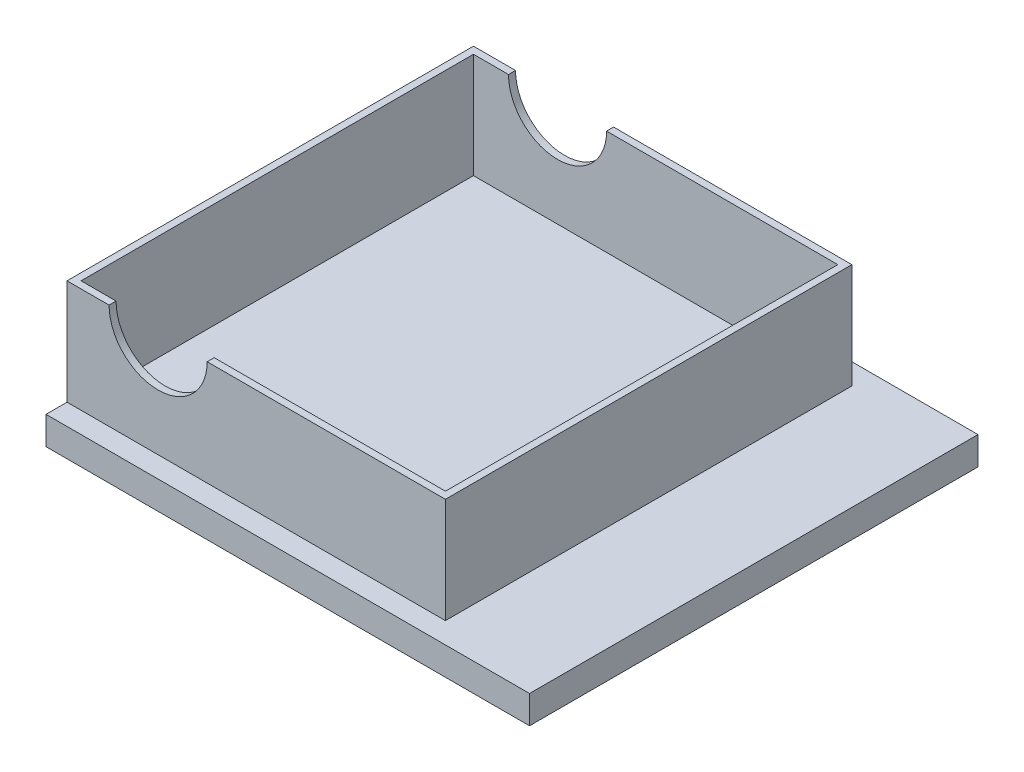
from build123d import *

# Parameters (mm, degrees)
ESQUISSE1_W             = 34.5
ESQUISSE1_H             = 32
BOSS_EXTRU_1_DEPTH      = 2
ESQUISSE1_4_W           = 27
ESQUISSE1_4_H           = 29
ESQUISSE1_4_W_2         = 26
ESQUISSE1_4_H_2         = 28
BOSS_EXTRU_2_DEPTH      = 9.5
ESQUISSE6_R             = 3.5
ENL_V_MAT_EXTRU_2_DEPTH = 0.5
ENL_V_START             = -0.5
ESQUISSE5_R             = 3.5
ENL_V_MAT_EXTRU_3_DEPTH = 0.5


with BuildPart() as part:
    # Esquisse1 → Boss.-Extru.1 (new body)
    with BuildSketch(Plane(origin=(0, 0, 0), x_dir=(1, 0, 0), z_dir=(0, 1, 0))):
        with Locations((-3.171052632, 11.289473684)):
            Rectangle(ESQUISSE1_W, ESQUISSE1_H)
    extrude(amount=BOSS_EXTRU_1_DEPTH)

    # Esquisse1_4 → Boss.-Extru.2 (add)
    with BuildSketch(Plane(origin=(0, 0, 0), x_dir=(1, 0, 0), z_dir=(0, 1, 0))):
        with Locations((-6.921052632, 11.289473684)):
            Rectangle(ESQUISSE1_4_W, ESQUISSE1_4_H)
        with Locations((-6.921052632, 11.289473684)):
            Rectangle(ESQUISSE1_4_W_2, ESQUISSE1_4_H_2, mode=Mode.SUBTRACT)
    extrude(amount=BOSS_EXTRU_2_DEPTH)

    # Esquisse6 → Enlèv. mat.-Extru.2 (cut)
    with BuildSketch(Plane.XY.offset(3.210526316)):
        with Locations((-13.921052632, 9.5)):
            Circle(ESQUISSE6_R)
    extrude(amount=-ENL_V_MAT_EXTRU_2_DEPTH, mode=Mode.SUBTRACT)

    # Esquisse5 → Enlèv. mat.-Extru.3 (cut)
    with BuildSketch(Plane(origin=(0, 0, -25.789473684), x_dir=(-1, 0, 0), z_dir=(0, 0, -1)).offset(ENL_V_START)):
        with Locations((13.921052632, 9.5)):
            Circle(ESQUISSE5_R)
    extrude(amount=ENL_V_MAT_EXTRU_3_DEPTH, mode=Mode.SUBTRACT)


solid = part.part
